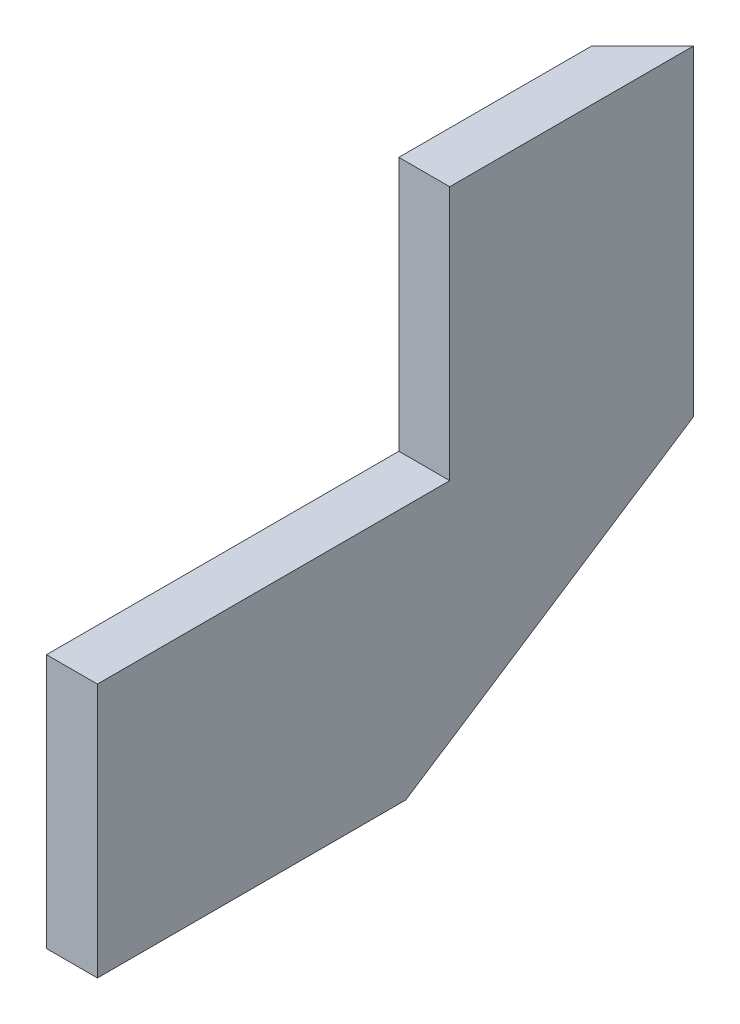
from build123d import *

# Parameters (mm, degrees)
BOSS_EXTRUDE2_DEPTH = 38.1
CUT_EXTRUDE1_REACH  = 383


with BuildPart() as part:
    # Sketch1 → Boss-Extrude2 (new body)
    with BuildSketch(Plane(origin=(0, 0, 0), x_dir=(0, 0, -1), z_dir=(1, 0, 0))):
        Polygon((230.790126839, 0), (446.057536726, 140.777827649), (446.057536726, 381), (263.652, 381), (263.652, 190.5), (0, 190.5), (0, 0), align=None)
    extrude(amount=BOSS_EXTRUDE2_DEPTH)

    # Sketch2 → Cut-Extrude1 (cut, up to next)
    with BuildSketch(Plane(origin=(0, 381, 0), x_dir=(1, 0, 0), z_dir=(0, 1, 0)), mode=Mode.PRIVATE) as cut_extrude1_sk1:
        Polygon((38.1, 446.057536726), (0, 407.957536726), (0, 446.057536726), align=None)
    cut_extrude1_tool1 = extrude(cut_extrude1_sk1.sketch, amount=-CUT_EXTRUDE1_REACH, mode=Mode.PRIVATE) & part.part
    add(cut_extrude1_tool1.solids().sort_by_distance((12.7, 381, -433.357537))[0], mode=Mode.SUBTRACT)


solid = part.part
